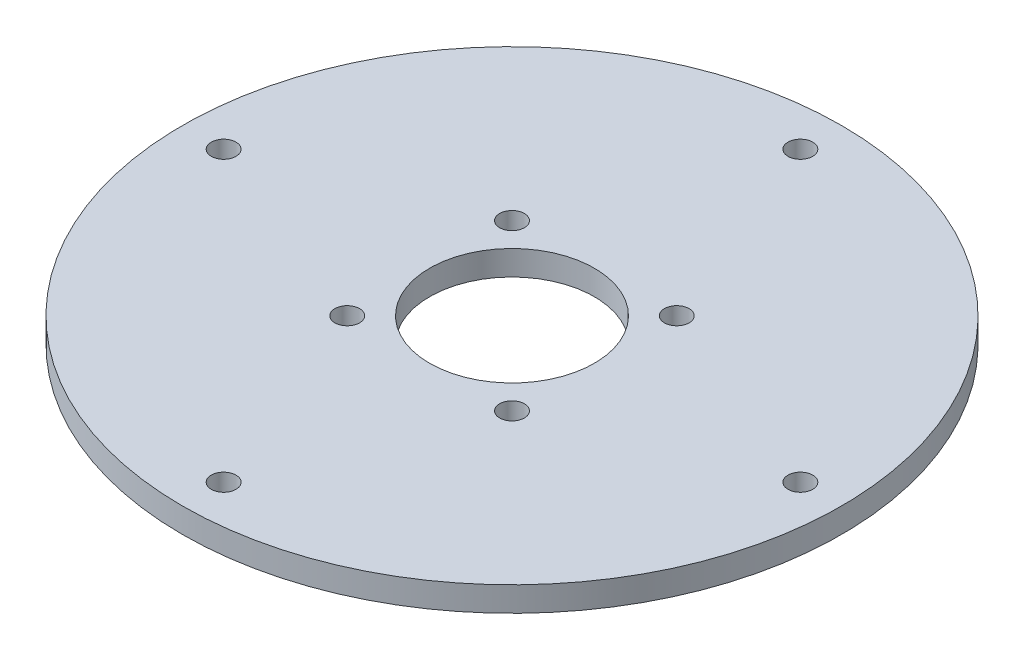
from build123d import *

# Parameters (mm, degrees)
SKETCH1_R           = 40
SKETCH1_R_2         = 1.5
BOSS_EXTRUDE1_DEPTH = 3
SKETCH2_R           = 1.5
CUT_EXTRUDE1_DEPTH  = 3
SKETCH3_R           = 10
CUT_EXTRUDE2_DEPTH  = 10


with BuildPart() as part:
    # Sketch1 → Boss-Extrude1 (new body)
    with BuildSketch(Plane(origin=(0, 0, 0), x_dir=(1, 0, 0), z_dir=(0, 1, 0))):
        Circle(SKETCH1_R)
        with Locations((0, 35)):
            Circle(SKETCH1_R_2, mode=Mode.SUBTRACT)
        with Locations((35, 0)):
            Circle(SKETCH1_R_2, mode=Mode.SUBTRACT)
        with Locations((0, -35)):
            Circle(SKETCH1_R_2, mode=Mode.SUBTRACT)
        with Locations((-35, 0)):
            Circle(SKETCH1_R_2, mode=Mode.SUBTRACT)
    extrude(amount=BOSS_EXTRUDE1_DEPTH)

    # Sketch2 → Cut-Extrude1 (cut)
    with BuildSketch(Plane(origin=(0, 3, 0), x_dir=(1, 0, 0), z_dir=(0, 1, 0))):
        with Locations((10, 10)):
            Circle(SKETCH2_R)
        with Locations((-10, 10)):
            Circle(SKETCH2_R)
        with Locations((-10, -10)):
            Circle(SKETCH2_R)
        with Locations((10, -10)):
            Circle(SKETCH2_R)
    extrude(amount=-CUT_EXTRUDE1_DEPTH, mode=Mode.SUBTRACT)

    # Sketch3 → Cut-Extrude2 (cut)
    with BuildSketch(Plane(origin=(0, 3, 0), x_dir=(1, 0, 0), z_dir=(0, 1, 0))):
        Circle(SKETCH3_R)
    extrude(amount=-CUT_EXTRUDE2_DEPTH, mode=Mode.SUBTRACT)


solid = part.part
